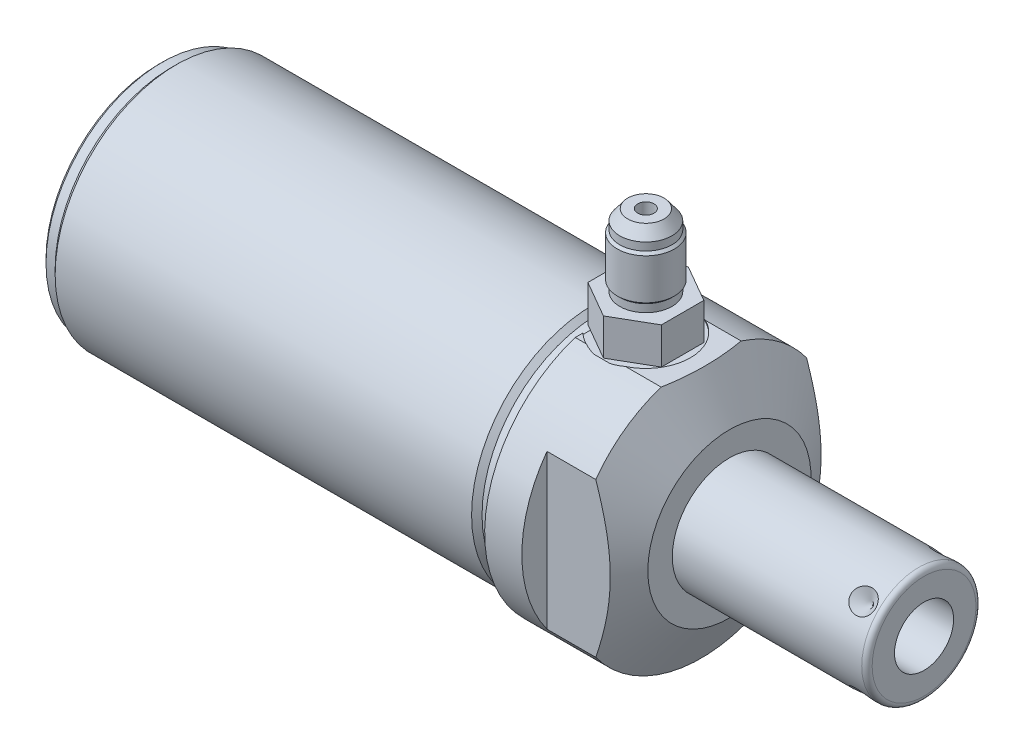
from build123d import *

# Parameters (mm, degrees)
SKETCH1_R           = 25.4
EXTRUDE1_DEPTH      = 22.225
EXTRUDE1_DEPTH_BACK = 88.9
CUT_EXTRUDE1_REACH  = 90.9
SKETCH2_R           = 25.4
SKETCH2_R_2         = 23.622
CUT_EXTRUDE3_REACH  = 31.464
CUT_EXTRUDE3_START  = -7.239
CUT_EXTRUDE4_DEPTH  = 7.239
SKETCH20_R          = 8.6614
CUT_EXTRUDE5_DEPTH  = 0.254
CHAMFER1_SIZE       = 0.762
EXTRUDE3_DEPTH      = 7.112
CIRPATTERN1_COUNT   = 4


with BuildPart() as part:
    # Sketch1 → Extrude1 (new body, two sides)
    with BuildSketch(Plane(origin=(0, 0, 0), x_dir=(0, 0, -1), z_dir=(1, 0, 0))) as extrude1_sk:
        Circle(SKETCH1_R)
    extrude(amount=EXTRUDE1_DEPTH)
    extrude(extrude1_sk.sketch, amount=-EXTRUDE1_DEPTH_BACK)

    # Sketch2 → Cut-Extrude1 (cut, up to next)
    with BuildSketch(Plane(origin=(0, 0, 0), x_dir=(0, 0, -1), z_dir=(1, 0, 0)), mode=Mode.PRIVATE) as cut_extrude1_sk1:
        Circle(SKETCH2_R)
        Circle(SKETCH2_R_2, mode=Mode.SUBTRACT)
    cut_extrude1_tool1 = extrude(cut_extrude1_sk1.sketch, amount=-CUT_EXTRUDE1_REACH, mode=Mode.PRIVATE) & part.part
    add(cut_extrude1_tool1.solids().sort_by_distance((0, 0, 24.68158))[0], mode=Mode.SUBTRACT)

    # Sketch4 → Cut-Extrude3 (cut, up to next)
    with BuildSketch(Plane.ZY.offset(CUT_EXTRUDE3_START), mode=Mode.PRIVATE) as cut_extrude3_sk1:
        with BuildLine():
            Line((20.5105, -14.982636275), (20.5105, 14.982636275))
            ThreePointArc((20.5105, 14.982636275), (25.4, 0), (20.5105, -14.982636275))
        make_face()
    cut_extrude3_tool1 = extrude(cut_extrude3_sk1.sketch, amount=-CUT_EXTRUDE3_REACH, mode=Mode.PRIVATE) & part.part
    add(cut_extrude3_tool1.solids().sort_by_distance((7.239, 0, 22.48339))[0], mode=Mode.SUBTRACT)
    # Sketch4 → Cut-Extrude3 (cut, up to next)
    with BuildSketch(Plane.ZY.offset(CUT_EXTRUDE3_START), mode=Mode.PRIVATE) as cut_extrude3_sk2:
        with BuildLine():
            Line((7.774889797, 24.1808), (-7.774889797, 24.1808))
            ThreePointArc((-7.774889797, 24.1808), (0, 25.4), (7.774889797, 24.1808))
        make_face()
    cut_extrude3_tool2 = extrude(cut_extrude3_sk2.sketch, amount=-CUT_EXTRUDE3_REACH, mode=Mode.PRIVATE) & part.part
    add(cut_extrude3_tool2.solids().sort_by_distance((7.239, 24.669497, 0))[0], mode=Mode.SUBTRACT)
    # Sketch4 → Cut-Extrude3 (cut, up to next)
    with BuildSketch(Plane.ZY.offset(CUT_EXTRUDE3_START), mode=Mode.PRIVATE) as cut_extrude3_sk3:
        with BuildLine():
            Line((-20.5105, -14.982636275), (-20.5105, 14.982636275))
            ThreePointArc((-20.5105, 14.982636275), (-25.4, 0), (-20.5105, -14.982636275))
        make_face()
    cut_extrude3_tool3 = extrude(cut_extrude3_sk3.sketch, amount=-CUT_EXTRUDE3_REACH, mode=Mode.PRIVATE) & part.part
    add(cut_extrude3_tool3.solids().sort_by_distance((7.239, 0, -22.48339))[0], mode=Mode.SUBTRACT)

    # Sketch19 → Cut-Extrude4 (cut)
    with BuildSketch(Plane(origin=(7.239, 0, 0), x_dir=(0, 0, -1), z_dir=(1, 0, 0))):
        with BuildLine():
            Line((-7.774889797, 24.1808), (7.774889797, 24.1808))
            ThreePointArc((7.774889797, 24.1808), (0, 25.4), (-7.774889797, 24.1808))
        make_face()
    extrude(amount=-CUT_EXTRUDE4_DEPTH, mode=Mode.SUBTRACT)

    # Sketch6 → Cut-Revolve2 (revolve, cut)
    with BuildSketch(Plane.XY, mode=Mode.PRIVATE) as cut_revolve2_sk:
        Polygon((2.061041849, 50.8), (22.225, 15.875), (22.225, 50.8), align=None)
    revolve(cut_revolve2_sk.sketch.rotate(Axis((1.052843941, 0, 0), (1, 0, 0)), 270), axis=Axis((1.052843941, 0, 0), (1, 0, 0)), mode=Mode.SUBTRACT)  # turned: the seam where the file's is

    # S2D0002 → Cut-Revolve3 (revolve, cut)
    with BuildSketch(Plane(origin=(5.969, 23.9268, 0), x_dir=(1, 0, 0), z_dir=(0, 0, 1)), mode=Mode.PRIVATE) as cut_revolve3_sk:
        Polygon((0, 0), (4.5466, 0), (4.106586662, -2.0701), (3.4544, -2.722286662), (3.4544, -12.192), (0, -12.192), align=None)
    revolve(cut_revolve3_sk.sketch.rotate(Axis((5.969, 11.1252, 0), (0, 1, 0)), 90), axis=Axis((5.969, 11.1252, 0), (0, 1, 0)), mode=Mode.SUBTRACT)  # turned: the seam where the file's is

    # Sketch20 → Cut-Extrude5 (cut)
    with BuildSketch(Plane(origin=(0, 24.1808, 0), x_dir=(1, 0, 0), z_dir=(0, 1, 0))):
        with Locations((5.969, 0)):
            Circle(SKETCH20_R)
    extrude(amount=-CUT_EXTRUDE5_DEPTH, mode=Mode.SUBTRACT)

    # Sketch9 → Cut-Revolve5 (revolve, cut)
    with BuildSketch(Plane.XY, mode=Mode.PRIVATE) as cut_revolve5_sk:
        Polygon((0, 23.622), (0, 22.606), (-3.302, 22.606), (-4.318, 23.622), align=None)
    revolve(cut_revolve5_sk.sketch.rotate(Axis((-4.5339, 0, 0), (1, 0, 0)), 90), axis=Axis((-4.5339, 0, 0), (1, 0, 0)), mode=Mode.SUBTRACT)  # turned: the seam where the file's is

    # Sketch11 → Cut-Revolve7 (revolve, cut)
    with BuildSketch(Plane.XY, mode=Mode.PRIVATE) as cut_revolve7_sk:
        Polygon((-88.9, 23.622), (-88.9, 22.606), (-86.36, 22.606), (-85.344, 23.622), align=None)
    revolve(cut_revolve7_sk.sketch.rotate(Axis((-89.0778, 0, 0), (1, 0, 0)), 90), axis=Axis((-89.0778, 0, 0), (1, 0, 0)), mode=Mode.SUBTRACT)  # turned: the seam where the file's is

    # Chamfer1
    chamfer1_edges = [part.edges().sort_by_distance(p)[0] for p in [
        (-88.9, 0, -22.606),
    ]]
    chamfer(chamfer1_edges, length=CHAMFER1_SIZE)

    # Sketch12 → Revolve1 (revolve)
    with BuildSketch(Plane(origin=(0, 0, 0), x_dir=(0, -1, 0), z_dir=(0, 0, 1)), mode=Mode.PRIVATE) as revolve1_sk:
        with BuildLine():
            Line((0, 22.225), (0, 60.0964))
            Line((0, 60.0964), (10.0965, 60.0964))
            ThreePointArc((10.0965, 60.0964), (10.81492049, 59.79882049), (11.1125, 59.0804))
            Line((11.1125, 59.0804), (11.1125, 22.225))
            Line((11.1125, 22.225), (0, 22.225))
        make_face()
    revolve(revolve1_sk.sketch.rotate(Axis((20.33143, 0, 0), (1, 0, 0)), 270), axis=Axis((20.33143, 0, 0), (1, 0, 0)))  # turned: the seam where the file's is

    # S2D0001 → Cut-Revolve8 (revolve, cut)
    with BuildSketch(Plane(origin=(60.0964, -5.7531, 0), x_dir=(0, -1, 0), z_dir=(0, 0, 1)), mode=Mode.PRIVATE) as cut_revolve8_sk:
        Polygon((0, 0), (0, -17.018), (-5.7531, -20.474811227), (-5.7531, 0), align=None)
    revolve(cut_revolve8_sk.sketch.rotate(Axis((38.597848211, 0, 0), (1, 0, 0)), 270), axis=Axis((38.597848211, 0, 0), (1, 0, 0)), mode=Mode.SUBTRACT)  # turned: the seam where the file's is

    # S2D0003 → Extrude3 (add)
    with BuildSketch(Plane.ZX.offset(23.9268)):
        Polygon((-4.12811216, 13.1191), (4.12811216, 13.1191), (8.256224319, 5.969), (4.12811216, -1.1811), (-4.12811216, -1.1811), (-8.256224319, 5.969), align=None)
    extrude(amount=EXTRUDE3_DEPTH)

    # Sketch16 → Revolve2 (revolve)
    with BuildSketch(Plane(origin=(0, 0, 0), x_dir=(0, -1, 0), z_dir=(0, 0, 1)), mode=Mode.PRIVATE) as revolve2_sk:
        Polygon((-31.0388, 11.049), (-32.5628, 11.049), (-33.0327, 11.5189), (-40.9575, 11.5189), (-41.4274, 11.049), (-42.9514, 11.049), (-45.0088, 9.498637897), (-45.0088, 7.5565), (-31.0388, 7.5565), align=None)
    revolve(revolve2_sk.sketch.rotate(Axis((5.969, 45.7073, 0), (0, -1, 0)), 90), axis=Axis((5.969, 45.7073, 0), (0, -1, 0)))  # turned: the seam where the file's is

    # Sketch17 → Cut-Revolve9 (revolve, cut)
    with BuildSketch(Plane(origin=(56.134, 7.857724106, -7.857724106), x_dir=(-1, 0, 0), z_dir=(0, -0.707106781, -0.707106781)), mode=Mode.PRIVATE) as cut_revolve9_sk:
        Polygon((0, 0), (2.413, 0), (0, -2.413), align=None)
    cut_revolve9 = revolve(cut_revolve9_sk.sketch.rotate(Axis((56.134, 6.06616301, -6.06616301), (0, 0.707106781, -0.707106781)), 90), axis=Axis((56.134, 6.06616301, -6.06616301), (0, 0.707106781, -0.707106781)), mode=Mode.SUBTRACT)  # turned: the seam where the file's is

    # CirPattern1: Cut-Revolve9 ×4 about axis
    cirpattern1_axis = Axis((-88.901, 0, 0), (1, 0, 0))
    for i in range(1, CIRPATTERN1_COUNT):
        add(cut_revolve9.rotate(cirpattern1_axis, i * 360 / CIRPATTERN1_COUNT), mode=Mode.SUBTRACT)


solid = part.part
